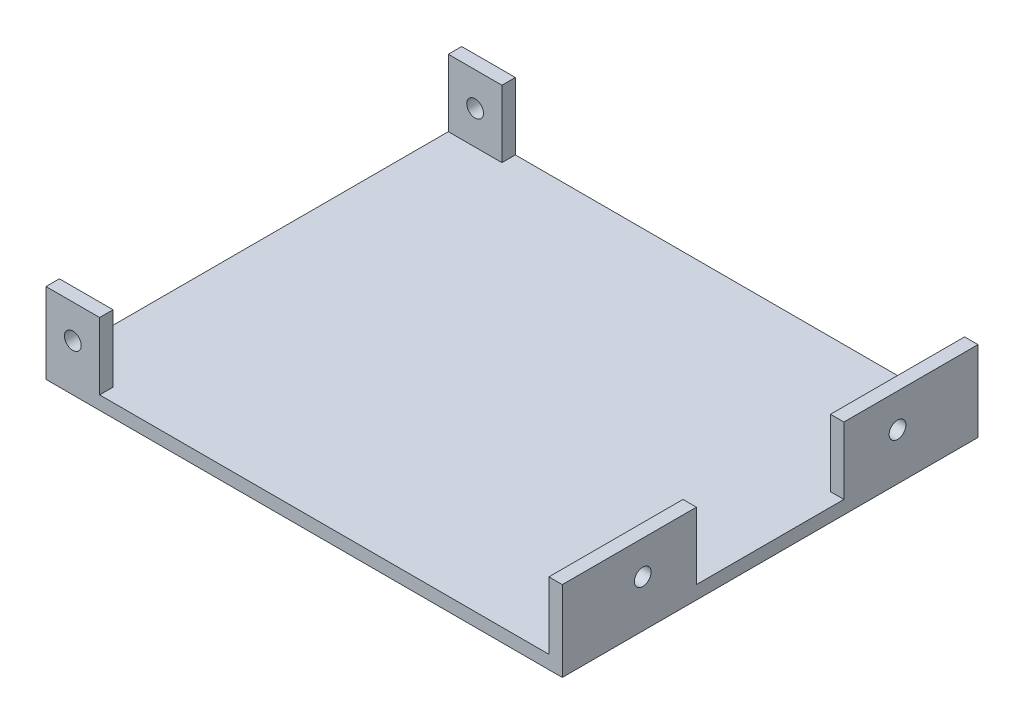
from build123d import *

# Parameters (mm, degrees)
SKETCH2_W           = 77
SKETCH2_H           = 62
BOSS_EXTRUDE1_DEPTH = 2
SKETCH3_W           = 8
SKETCH3_H           = 2
SKETCH3_W_2         = 2
SKETCH3_H_2         = 20
BOSS_EXTRUDE2_DEPTH = 10
SKETCH4_R           = 1.25
CUT_EXTRUDE1_DEPTH  = 63
CUT_EXTRUDE2_REACH  = 79
SKETCH5_R           = 1.25


with BuildPart() as part:
    # Sketch2 → Boss-Extrude1 (new body)
    with BuildSketch(Plane(origin=(0, 0, 0), x_dir=(1, 0, 0), z_dir=(0, 1, 0))):
        with Locations((-4.195246224, 15.849517589)):
            Rectangle(SKETCH2_W, SKETCH2_H)
    extrude(amount=BOSS_EXTRUDE1_DEPTH)

    # Sketch3 → Boss-Extrude2 (add)
    with BuildSketch(Plane(origin=(0, 2, 0), x_dir=(1, 0, 0), z_dir=(0, 1, 0))):
        with Locations((-38.695246224, -14.150482411)):
            Rectangle(SKETCH3_W, SKETCH3_H)
        with Locations((-38.695246224, 45.849517589)):
            Rectangle(SKETCH3_W, SKETCH3_H)
        with Locations((33.304753776, 36.849517589)):
            Rectangle(SKETCH3_W_2, SKETCH3_H_2)
        with Locations((33.304753776, -5.150482411)):
            Rectangle(SKETCH3_W_2, SKETCH3_H_2)
    extrude(amount=BOSS_EXTRUDE2_DEPTH)

    # Sketch4 → Cut-Extrude1 (cut, through all)
    with BuildSketch(Plane.XY.offset(15.150482411)):
        with Locations((-38.695246224, 7)):
            Circle(SKETCH4_R)
    extrude(amount=-CUT_EXTRUDE1_DEPTH, mode=Mode.SUBTRACT)

    # Sketch5 → Cut-Extrude2 (cut, up to next)
    with BuildSketch(Plane(origin=(34.304753776, 0, 0), x_dir=(0, 0, -1), z_dir=(1, 0, 0)), mode=Mode.PRIVATE) as cut_extrude2_sk1:
        with Locations((-3.150482411, 7)):
            Circle(SKETCH5_R)
    cut_extrude2_tool1 = extrude(cut_extrude2_sk1.sketch, amount=-CUT_EXTRUDE2_REACH, mode=Mode.PRIVATE) & part.part
    add(cut_extrude2_tool1.solids().sort_by_distance((34.304754, 7, 3.150482))[0], mode=Mode.SUBTRACT)
    # Sketch5 → Cut-Extrude2 (cut, up to next)
    with BuildSketch(Plane(origin=(34.304753776, 0, 0), x_dir=(0, 0, -1), z_dir=(1, 0, 0)), mode=Mode.PRIVATE) as cut_extrude2_sk2:
        with Locations((34.849517589, 7)):
            Circle(SKETCH5_R)
    cut_extrude2_tool2 = extrude(cut_extrude2_sk2.sketch, amount=-CUT_EXTRUDE2_REACH, mode=Mode.PRIVATE) & part.part
    add(cut_extrude2_tool2.solids().sort_by_distance((34.304754, 7, -34.849518))[0], mode=Mode.SUBTRACT)


solid = part.part
